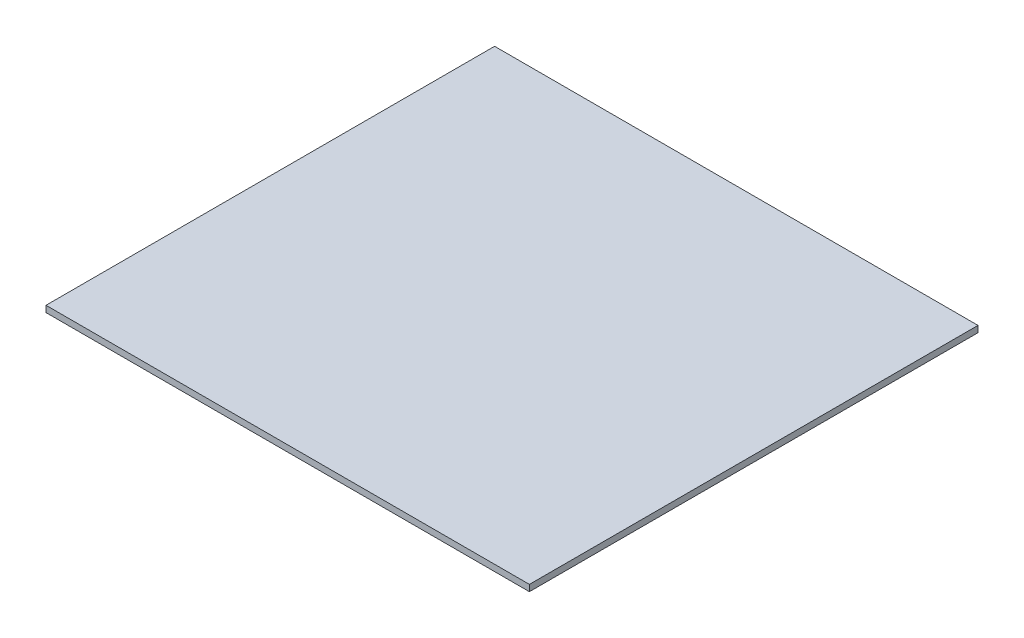
from build123d import *

# Parameters (mm, degrees)
BOSS_EXTRUDE1_DEPTH = 302.625
SKETCH3_W           = 760
SKETCH3_H           = 10
BOSS_EXTRUDE2_DEPTH = 50
SKETCH4_W           = 760
SKETCH4_H           = 10
BOSS_EXTRUDE3_DEPTH = 50


with BuildPart() as part:
    # Sketch2 → Boss-Extrude1 (new body, symmetric)
    with BuildSketch(Plane.XY):
        Polygon((0, 25), (-380, 25), (-380, 15), (-225, 15), (-225, 0), (0, 0), align=None)
    boss_extrude1 = extrude(amount=BOSS_EXTRUDE1_DEPTH, both=True)

    # Mirror1: Boss-Extrude1 across plane
    add(boss_extrude1.mirror(Plane(origin=(0, 25, 302.625), x_dir=(0, 0, 1), z_dir=(-1, 0, 0))))

    # Sketch3 → Boss-Extrude2 (add)
    with BuildSketch(Plane.XY.offset(302.625)):
        with Locations((0, 20)):
            Rectangle(SKETCH3_W, SKETCH3_H)
    extrude(amount=BOSS_EXTRUDE2_DEPTH)

    # Sketch4 → Boss-Extrude3 (add)
    with BuildSketch(Plane(origin=(0, 0, -302.625), x_dir=(-1, 0, 0), z_dir=(0, 0, -1))):
        with Locations((0, 20)):
            Rectangle(SKETCH4_W, SKETCH4_H)
    extrude(amount=BOSS_EXTRUDE3_DEPTH)


solid = part.part
